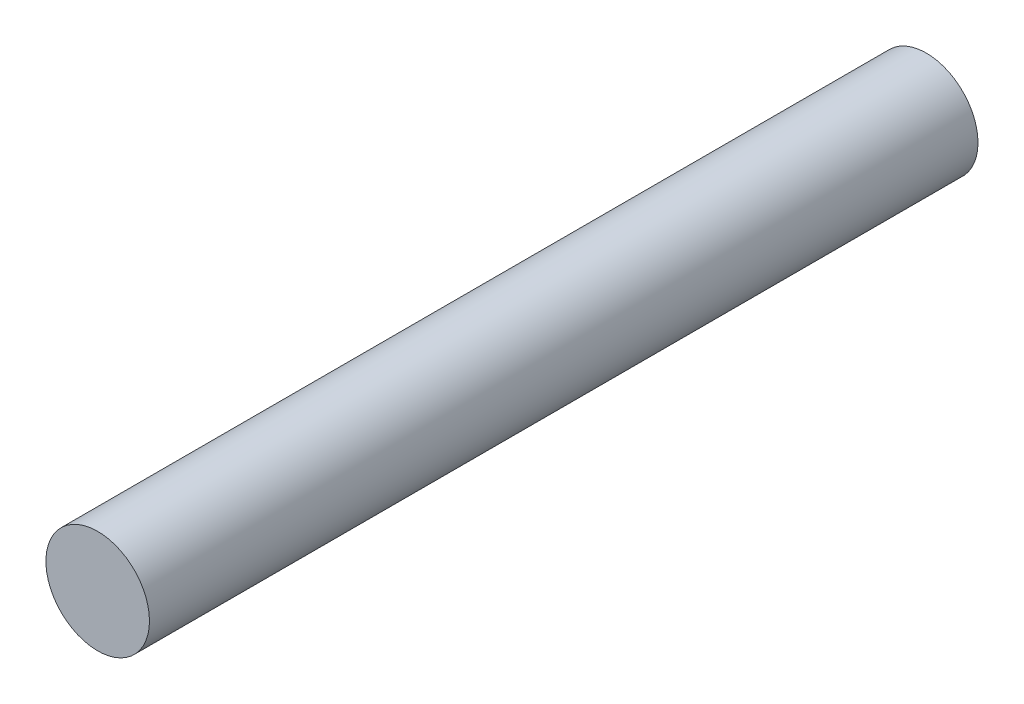
from build123d import *

# Parameters (mm, degrees)
SKETCH1_R           = 6.35
BOSS_EXTRUDE1_DEPTH = 101.6


with BuildPart() as part:
    # Sketch1 → Boss-Extrude1 (new body)
    with BuildSketch(Plane.XY):
        Circle(SKETCH1_R)
    extrude(amount=BOSS_EXTRUDE1_DEPTH)


solid = part.part
